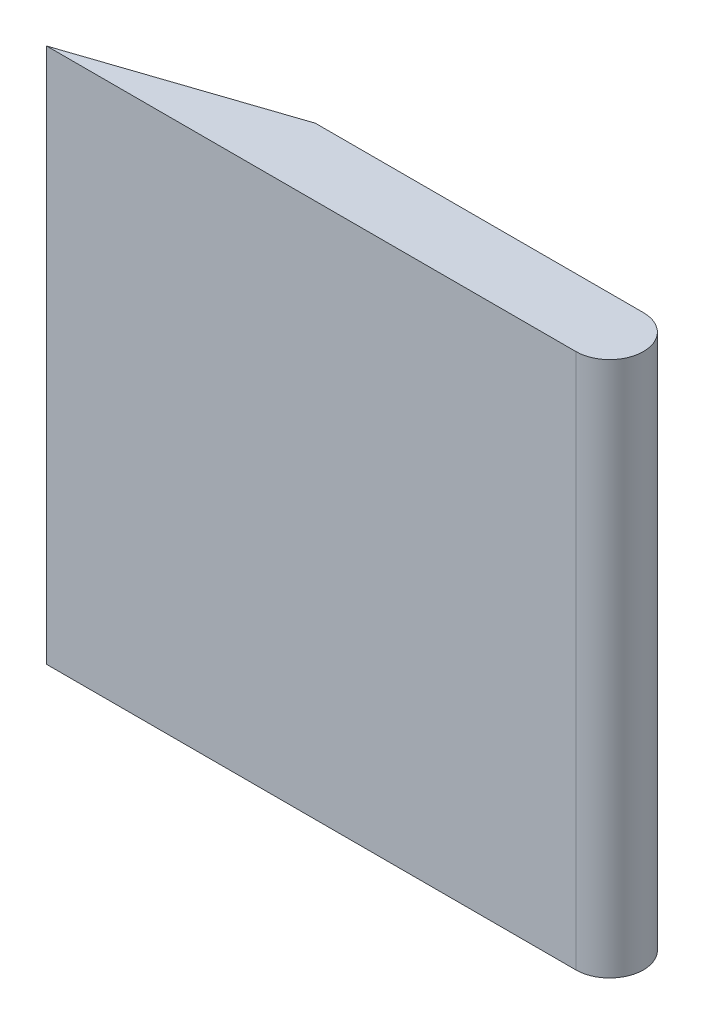
from build123d import *

# Parameters (mm, degrees)
BOSS_EXTRUDE1_DEPTH = 12.7


with BuildPart() as part:
    # Sketch1 → Boss-Extrude1 (new body)
    with BuildSketch(Plane(origin=(0, 0, 0), x_dir=(1, 0, 0), z_dir=(0, 1, 0))):
        with BuildLine():
            Line((0, -0.8), (-12.55, -0.8))
            Line((-12.55, -0.8), (-7.78, 0.8))
            Line((-7.78, 0.8), (0, 0.8))
            ThreePointArc((0, 0.8), (0.8, 0), (0, -0.8))
        make_face()
    extrude(amount=BOSS_EXTRUDE1_DEPTH)


solid = part.part
